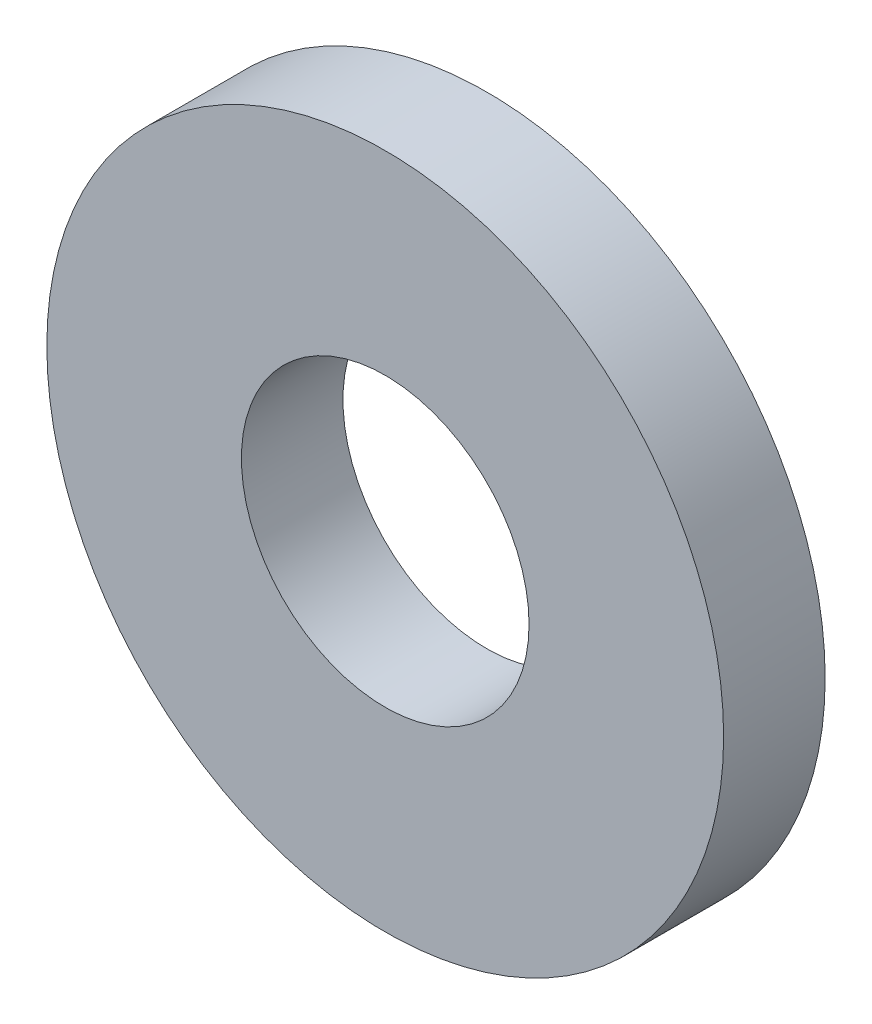
from build123d import *

# Parameters (mm, degrees)
SKETCH1_R           = 20
SKETCH1_R_2         = 8.5
BOSS_EXTRUDE1_DEPTH = 6


with BuildPart() as part:
    # Sketch1 → Boss-Extrude1 (new body)
    with BuildSketch(Plane.XY):
        with Locations((350, 80)):
            Circle(SKETCH1_R)
        with Locations((350, 80)):
            Circle(SKETCH1_R_2, mode=Mode.SUBTRACT)
    extrude(amount=BOSS_EXTRUDE1_DEPTH)


solid = part.part
